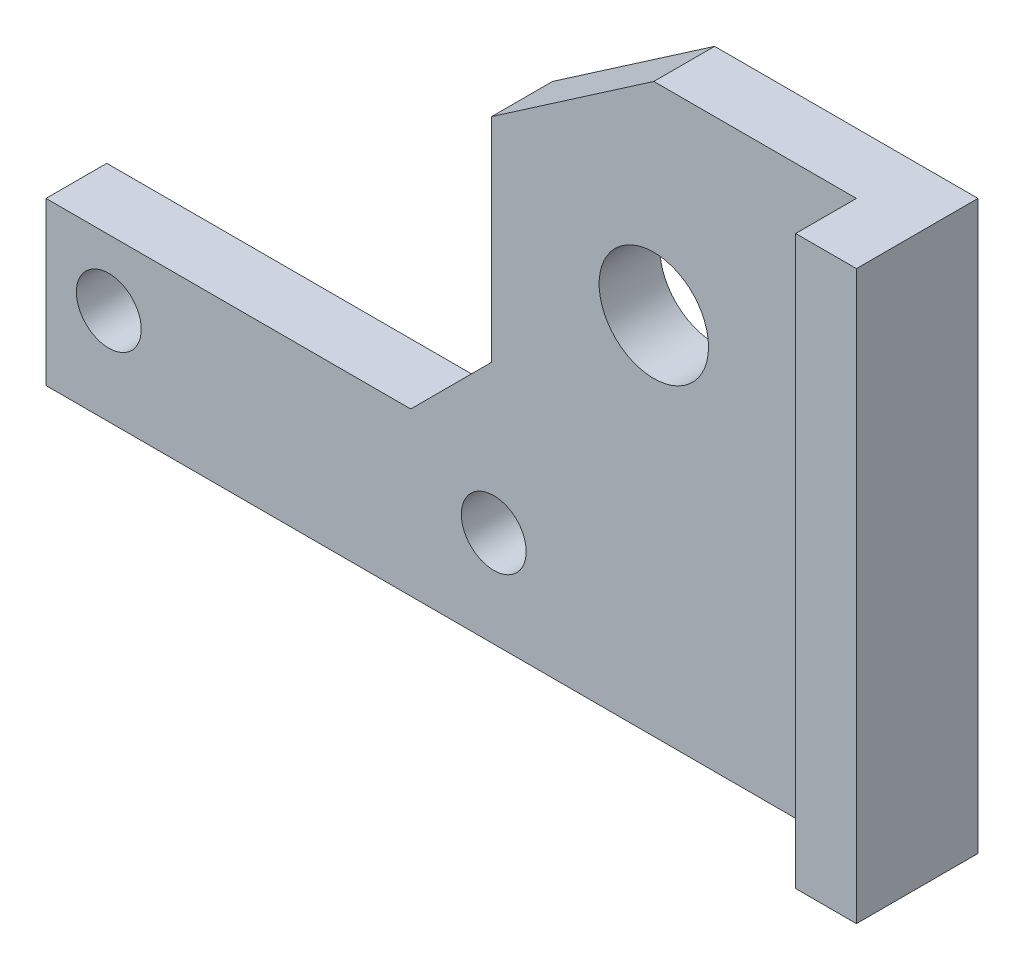
from build123d import *

# Parameters (mm, degrees)
SKETCH1_R           = 1.6
SKETCH1_R_2         = 2.7
BOSS_EXTRUDE1_DEPTH = 3
BOSS_EXTRUDE2_START = 3
SKETCH1_3_W         = 3
SKETCH1_3_H         = 28
BOSS_EXTRUDE2_DEPTH = 3
SKETCH1_5_W         = 3
SKETCH1_5_H         = 12
CUT_EXTRUDE2_DEPTH  = 1.25


with BuildPart() as part:
    # Sketch1 → Boss-Extrude1 (new body)
    with BuildSketch(Plane.XY):
        Polygon((0, 0), (0, 28), (-13, 28), (-21, 22.5), (-21, 12), (-25, 8), (-43, 8), (-43, 0), align=None)
        with Locations((-39.9, 4.75)):
            Circle(SKETCH1_R, mode=Mode.SUBTRACT)
        with Locations((-13, 18)):
            Circle(SKETCH1_R_2, mode=Mode.SUBTRACT)
        with Locations((-20.9, 4.75)):
            Circle(SKETCH1_R, mode=Mode.SUBTRACT)
    extrude(amount=BOSS_EXTRUDE1_DEPTH)

    # Sketch1_3 → Boss-Extrude2 (add)
    with BuildSketch(Plane.XY.offset(BOSS_EXTRUDE2_START)):
        with Locations((-1.5, 14)):
            Rectangle(SKETCH1_3_W, SKETCH1_3_H)
    extrude(amount=BOSS_EXTRUDE2_DEPTH)

    # Sketch1_5 → Cut-Extrude2 (cut)
    with BuildSketch(Plane.XY):
        with Locations((-15, 6)):
            Rectangle(SKETCH1_5_W, SKETCH1_5_H)
    extrude(amount=CUT_EXTRUDE2_DEPTH, mode=Mode.SUBTRACT)


solid = part.part
